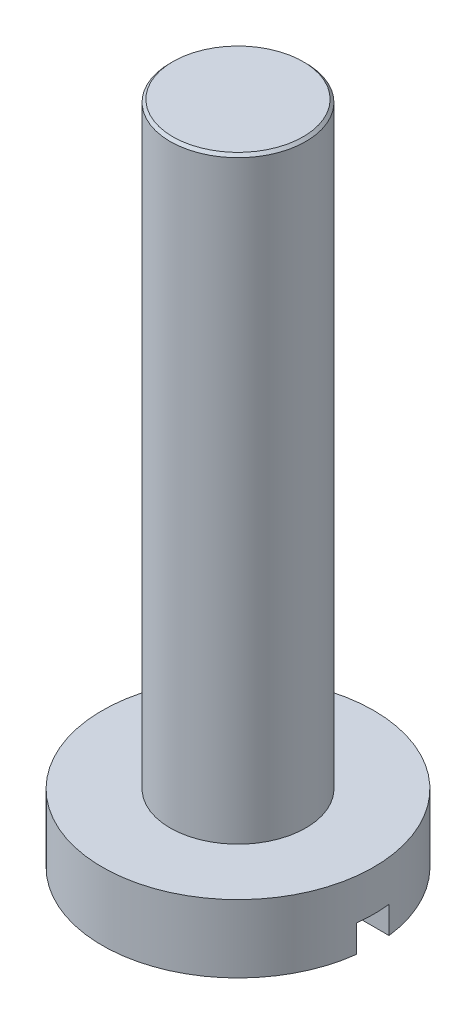
from build123d import *

# Parameters (mm, degrees)
SKETCH1_R           = 1.25
BOSS_EXTRUDE1_DEPTH = 11
SKETCH2_R           = 2.5
BOSS_EXTRUDE2_DEPTH = 1.25
SKETCH3_W           = 8.196351728
SKETCH3_H           = 0.6
CUT_EXTRUDE1_DEPTH  = 0.5
CHAMFER1_SIZE       = 0.05


with BuildPart() as part:
    # Sketch1 → Boss-Extrude1 (new body)
    with BuildSketch(Plane(origin=(0, 0, 0), x_dir=(1, 0, 0), z_dir=(0, 1, 0))):
        Circle(SKETCH1_R)
    extrude(amount=BOSS_EXTRUDE1_DEPTH)

    # Chamfer1
    chamfer1_edges = [part.edges().sort_by_distance(p)[0] for p in [
        (-1.25, 11, 0),
    ]]
    chamfer(chamfer1_edges, length=CHAMFER1_SIZE)


with BuildPart() as body_2:
    # Sketch2 → Boss-Extrude2 (new body)
    with BuildSketch(Plane.XZ):
        Circle(SKETCH2_R)
    extrude(amount=BOSS_EXTRUDE2_DEPTH)

    # Sketch3 → Cut-Extrude1 (cut)
    with BuildSketch(Plane.XZ.offset(1.25)):
        Rectangle(SKETCH3_W, SKETCH3_H)
    extrude(amount=-CUT_EXTRUDE1_DEPTH, mode=Mode.SUBTRACT)


solid = Compound([part.part, body_2.part])
